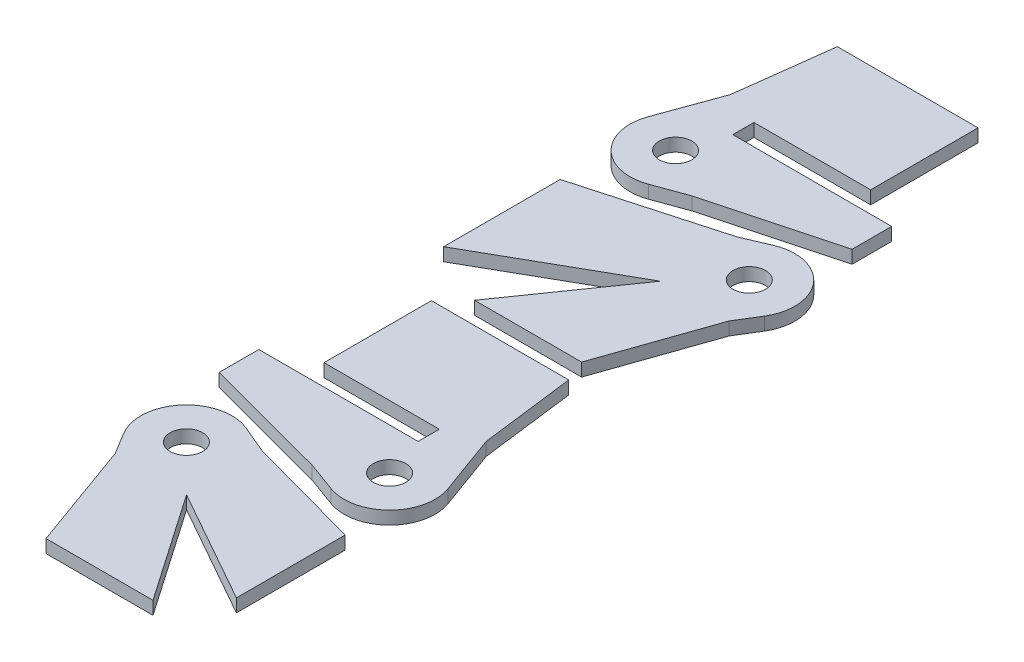
from build123d import *

# Parameters (mm, degrees)
SKETCH1_R             = 3.175
BOSS_EXTRUDE1_DEPTH   = 2.54
BOSS_EXTRUDE1_2_DEPTH = 2.54
BOSS_EXTRUDE1_3_DEPTH = 2.54
BOSS_EXTRUDE1_4_DEPTH = 2.54


with BuildPart() as part:
    # Sketch1 → Boss-Extrude1 (new body)
    with BuildSketch(Plane(origin=(0, 0, 0), x_dir=(1, 0, 0), z_dir=(0, 1, 0))):
        with BuildLine():
            Line((121.160023429, 85.841348265), (125.425493445, 97.560630816))
            Line((125.425493445, 97.560630816), (127.767090588, 116.096280816))
            Line((127.767090588, 116.096280816), (155.185130831, 116.096280816))
            Line((155.185130831, 116.096280816), (155.185130831, 95.170280682))
            Line((155.185130831, 95.170280682), (132.426730831, 95.170280682))
            Line((132.426730831, 95.170280682), (132.426730831, 91.042780682))
            Line((132.426730831, 91.042780682), (138.776730831, 91.042780682))
            Line((138.776730831, 91.042780682), (163.408380831, 91.042780682))
            Line((163.408380831, 91.042780682), (163.408380831, 83.325571221))
            Line((163.408380831, 83.325571221), (138.777449902, 76.71190856))
            Line((138.777449902, 76.71190856), (132.554449902, 74.446921792))
            ThreePointArc((132.554449902, 74.446921792), (123.227711543, 76.514609906), (121.160023429, 85.841348265))
        make_face()
        with Locations((129.513890828, 82.800789191)):
            Circle(SKETCH1_R, mode=Mode.SUBTRACT)
    extrude(amount=BOSS_EXTRUDE1_DEPTH)


with BuildPart() as body_2:
    # Sketch1 → Boss-Extrude1 2 (new body)
    with BuildSketch(Plane(origin=(0, 0, 0), x_dir=(1, 0, 0), z_dir=(0, 1, 0))):
        with BuildLine():
            Line((123.471705783, -18.7400603), (126.06306228, -23.020584327))
            Line((126.06306228, -23.020584327), (133.672193007, -44.109551442))
            Line((133.672193007, -44.109551442), (154.5296138, -44.109551442))
            Line((154.5296138, -44.109551442), (139.986741583, -23.020584327))
            Line((139.986741583, -23.020584327), (162.246407354, -35.558143344))
            Line((162.246407354, -35.558143344), (162.246407354, -14.346055224))
            Line((162.246407354, -14.346055224), (139.986741583, -8.248147359))
            Line((139.986741583, -8.248147359), (134.534580264, -5.946185543))
            ThreePointArc((134.534580264, -5.946185543), (124.352083456, -8.321347722), (123.471705783, -18.7400603))
        make_face()
        with Locations((131.07669771, -14.136127438)):
            Circle(SKETCH1_R, mode=Mode.SUBTRACT)
    extrude(amount=BOSS_EXTRUDE1_2_DEPTH)


with BuildPart() as body_3:
    # Sketch1 → Boss-Extrude1 3 (new body)
    with BuildSketch(Plane(origin=(0, 0, 0), x_dir=(1, 0, 0), z_dir=(0, 1, 0))):
        with BuildLine():
            Line((155.0793846, 76.307406469), (150.101485678, 74.188258913))
            Line((150.101485678, 74.188258913), (123.162108904, 66.641301888))
            Line((123.162108904, 66.641301888), (123.162108904, 43.934410807))
            Line((123.162108904, 43.934410807), (150.101485678, 59.231888247))
            Line((150.101485678, 59.231888247), (135.217678068, 37.904383964))
            Line((135.217678068, 37.904383964), (156.089383515, 37.904383964))
            Line((156.089383515, 37.904383964), (163.529451504, 59.231888247))
            Line((163.529451504, 59.231888247), (166.135842398, 63.4734909))
            ThreePointArc((166.135842398, 63.4734909), (165.296811041, 73.930206812), (155.0793846, 76.307406469))
        make_face()
        with Locations((158.561551945, 68.127760353)):
            Circle(SKETCH1_R, mode=Mode.SUBTRACT)
    extrude(amount=BOSS_EXTRUDE1_3_DEPTH)


with BuildPart() as body_4:
    # Sketch1 → Boss-Extrude1 4 (new body)
    with BuildSketch(Plane(origin=(0, 0, 0), x_dir=(1, 0, 0), z_dir=(0, 1, 0))):
        with BuildLine():
            Line((153.04882444, -7.890445491), (147.201117261, -5.762054139))
            Line((147.201117261, -5.762054139), (122.497855638, 0.815592547))
            Line((122.497855638, 0.815592547), (122.497855638, 8.563545861))
            Line((122.497855638, 8.563545861), (147.201117261, 8.563545861))
            Line((147.201117261, 8.563545861), (153.551117261, 8.563545861))
            Line((153.551117261, 8.563545861), (153.551117261, 12.691045861))
            Line((153.551117261, 12.691045861), (131.07669771, 12.691045861))
            Line((131.07669771, 12.691045861), (131.07669771, 33.631531264))
            Line((131.07669771, 33.631531264), (157.852275877, 33.631531264))
            Line((157.852275877, 33.631531264), (160.177780898, 15.223263533))
            Line((160.177780898, 15.223263533), (164.443250913, 3.503980982))
            ThreePointArc((164.443250913, 3.503980982), (162.375562799, -5.822757377), (153.04882444, -7.890445491))
        make_face()
        with Locations((156.089383515, 0.463421908)):
            Circle(SKETCH1_R, mode=Mode.SUBTRACT)
    extrude(amount=BOSS_EXTRUDE1_4_DEPTH)


solid = Compound([part.part, body_2.part, body_3.part, body_4.part])
